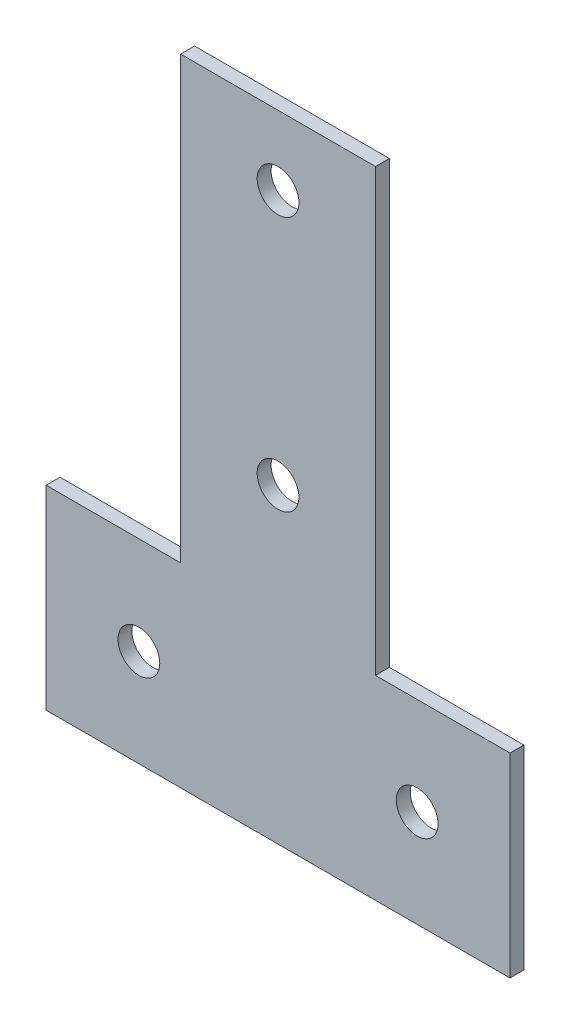
from build123d import *

# Parameters (mm, degrees)
SKETCH_1_R      = 4.5
EXTRUDE_1_DEPTH = 3


with BuildPart() as part:
    # Эскиз1 → Бобышка-Вытянуть1 (new body)
    with BuildSketch(Plane.XY):
        Polygon((-50, 0), (50, 0), (50, 42), (21, 42), (21, 137), (-21, 137), (-21, 42), (-50, 42), align=None)
        with Locations((0, 122)):
            Circle(SKETCH_1_R, mode=Mode.SUBTRACT)
        with Locations((0, 67)):
            Circle(SKETCH_1_R, mode=Mode.SUBTRACT)
        with Locations((-30, 21)):
            Circle(SKETCH_1_R, mode=Mode.SUBTRACT)
        with Locations((30, 21)):
            Circle(SKETCH_1_R, mode=Mode.SUBTRACT)
    extrude(amount=EXTRUDE_1_DEPTH)


solid = part.part
